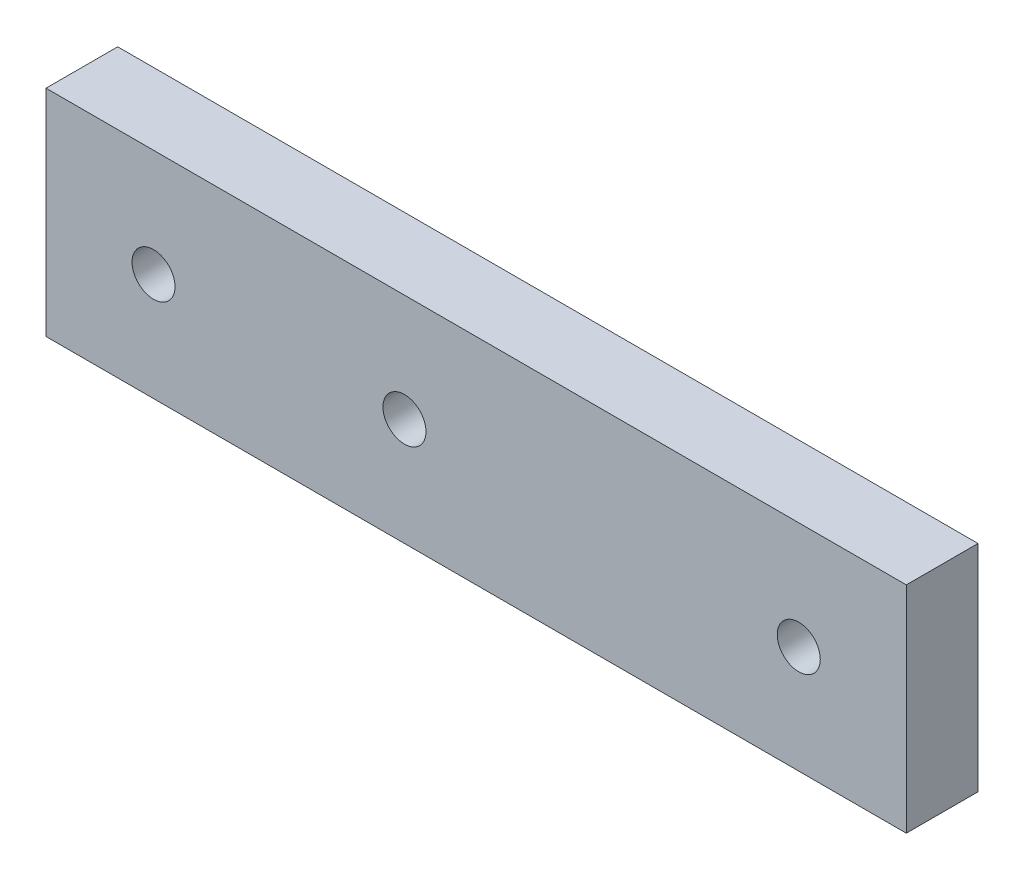
from build123d import *

# Parameters (mm, degrees)
SKETCH2_W           = 60
SKETCH2_H           = 15
SKETCH2_R           = 1.5
BOSS_EXTRUDE1_DEPTH = 5


with BuildPart() as part:
    # Sketch2 → Boss-Extrude1 (new body)
    with BuildSketch(Plane.XY):
        with Locations((-30, 7.5)):
            Rectangle(SKETCH2_W, SKETCH2_H)
        with Locations((-52.5, 7.5)):
            Circle(SKETCH2_R, mode=Mode.SUBTRACT)
        with Locations((-35, 7.5)):
            Circle(SKETCH2_R, mode=Mode.SUBTRACT)
        with Locations((-7.5, 7.5)):
            Circle(SKETCH2_R, mode=Mode.SUBTRACT)
    extrude(amount=BOSS_EXTRUDE1_DEPTH)


solid = part.part
